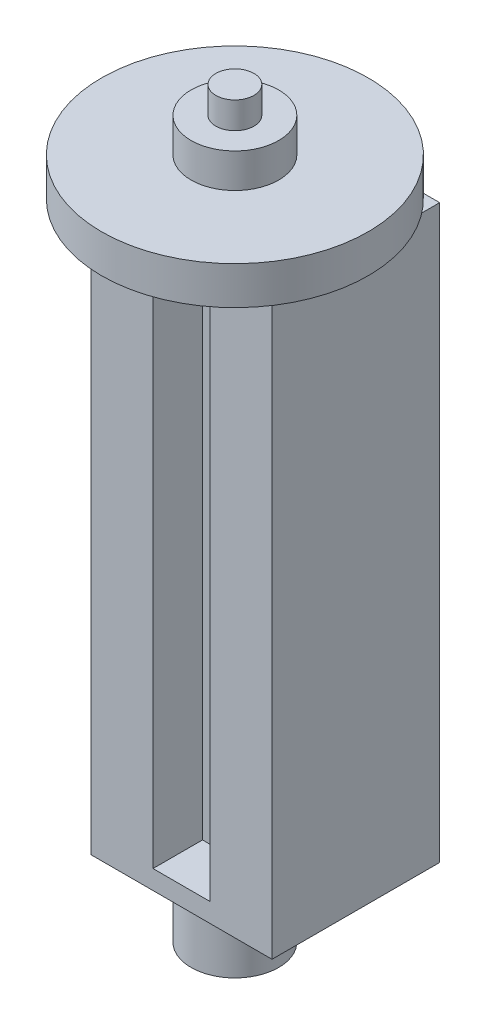
from build123d import *

# Parameters (mm, degrees)
ESBO_O1_W                     = 4.75
ESBO_O1_H                     = 15
RESSALTO_EXTRUS_O1_DEPTH      = 4.4
ESBO_O2_R                     = 1.15
RESSALTO_EXTRUS_O2_DEPTH      = 1.5
RESSALTO_EXTRUS_O2_DEPTH_BACK = 18
ESBO_O3_R                     = 3.5
RESSALTO_EXTRUS_O3_DEPTH      = 1
ESBO_O4_R                     = 1.15
ESBO_O4_R_2                   = 0.5
CORTE_EXTRUS_O1_DEPTH         = 0.7
ESBO_O5_W                     = 1.5
ESBO_O5_H                     = 14
CORTE_EXTRUS_O2_DEPTH         = 1.3


with BuildPart() as part:
    # Esboço1 → Ressalto-extrusão1 (new body)
    with BuildSketch(Plane.XY):
        Rectangle(ESBO_O1_W, ESBO_O1_H)
    extrude(amount=RESSALTO_EXTRUS_O1_DEPTH)

    # Esboço2 → Ressalto-extrusão2 (add, two sides)
    with BuildSketch(Plane.XZ.offset(7.5)) as ressalto_extrus_o2_sk:
        with Locations((0, 3)):
            Circle(ESBO_O2_R)
    extrude(amount=RESSALTO_EXTRUS_O2_DEPTH)
    extrude(ressalto_extrus_o2_sk.sketch, amount=-RESSALTO_EXTRUS_O2_DEPTH_BACK)

    # Esboço3 → Ressalto-extrusão3 (add)
    with BuildSketch(Plane(origin=(0, 8.9, 0), x_dir=(1, 0, 0), z_dir=(0, 1, 0))):
        with Locations((0, -3)):
            Circle(ESBO_O3_R)
    extrude(amount=-RESSALTO_EXTRUS_O3_DEPTH)

    # Esboço4 → Corte-extrusão1 (cut)
    with BuildSketch(Plane(origin=(0, 10.5, 0), x_dir=(1, 0, 0), z_dir=(0, 1, 0))):
        with Locations((0, -3)):
            Circle(ESBO_O4_R)
        with Locations((0, -3)):
            Circle(ESBO_O4_R_2, mode=Mode.SUBTRACT)
    extrude(amount=-CORTE_EXTRUS_O1_DEPTH, mode=Mode.SUBTRACT)

    # Esboço5 → Corte-extrusão2 (cut)
    with BuildSketch(Plane.XY.offset(4.4)):
        Rectangle(ESBO_O5_W, ESBO_O5_H)
    extrude(amount=-CORTE_EXTRUS_O2_DEPTH, mode=Mode.SUBTRACT)


solid = part.part
